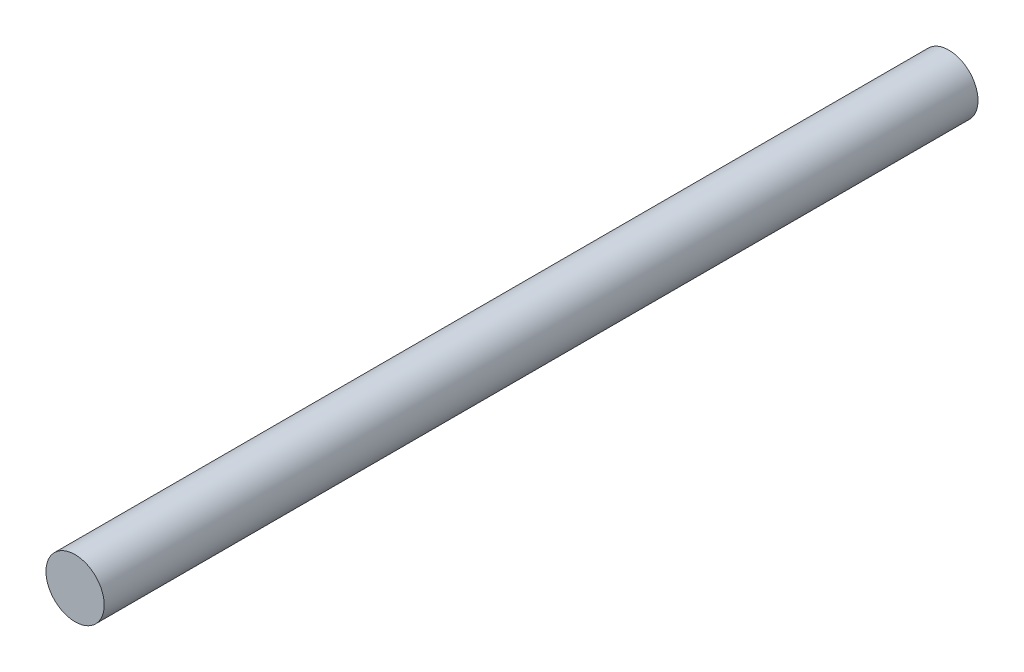
from build123d import *

# Parameters (mm, degrees)
SKETCH1_R           = 50
BOSS_EXTRUDE1_DEPTH = 750


with BuildPart() as part:
    # Sketch1 → Boss-Extrude1 (new body, symmetric)
    with BuildSketch(Plane.XY):
        Circle(SKETCH1_R)
    extrude(amount=BOSS_EXTRUDE1_DEPTH, both=True)


solid = part.part
